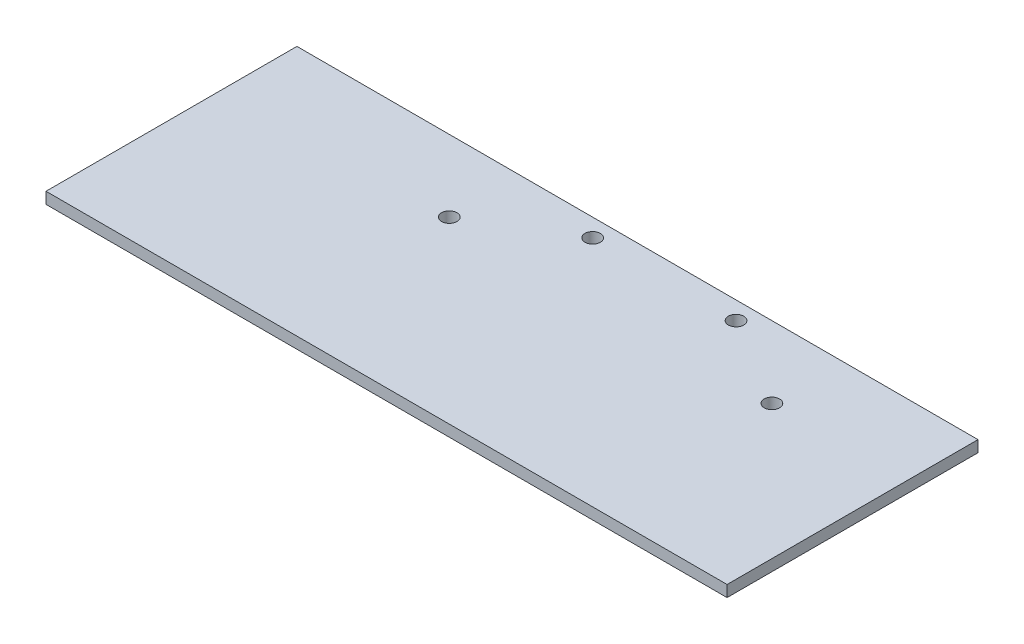
from build123d import *

# Parameters (mm, degrees)
SKETCH1_W           = 190
SKETCH1_H           = 70
SKETCH1_R           = 2.15
BOSS_EXTRUDE1_DEPTH = 1.5875


with BuildPart() as part:
    # Sketch1 → Boss-Extrude1 (new body, symmetric)
    with BuildSketch(Plane(origin=(0, 0, 0), x_dir=(1, 0, 0), z_dir=(0, 1, 0))):
        with Locations((-12.5, -30)):
            Rectangle(SKETCH1_W, SKETCH1_H)
        with Locations((-20, 0)):
            Circle(SKETCH1_R, mode=Mode.SUBTRACT)
        with Locations((20, 0)):
            Circle(SKETCH1_R, mode=Mode.SUBTRACT)
        with Locations((45, -15)):
            Circle(SKETCH1_R, mode=Mode.SUBTRACT)
        with Locations((-45, -15)):
            Circle(SKETCH1_R, mode=Mode.SUBTRACT)
    extrude(amount=BOSS_EXTRUDE1_DEPTH, both=True)


solid = part.part
